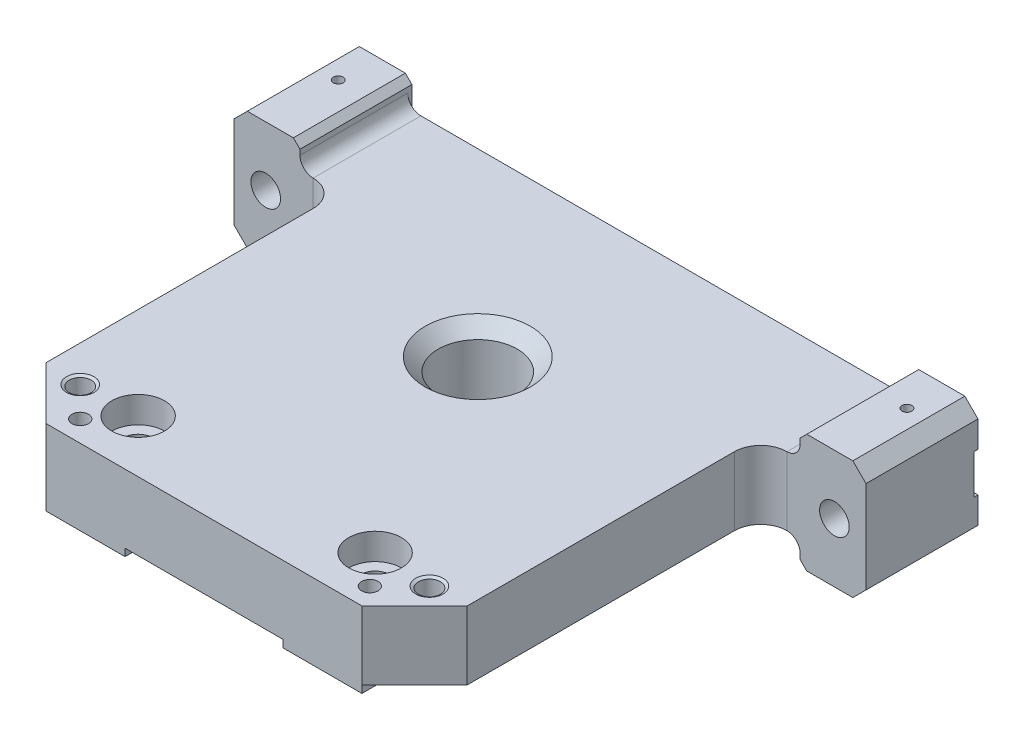
from build123d import *

# Parameters (mm, degrees)
SKETCH1_W                                     = 152.4
SKETCH1_H                                     = 16.51
EXTRUDE1_DEPTH                                = 11.1252
SKETCH2_W                                     = 101.6
SKETCH2_H                                     = 16.51
EXTRUDE2_DEPTH                                = 99.3648
SKETCH4_W                                     = 19.05
SKETCH4_H                                     = 19.05
EXTRUDE4_DEPTH                                = 2.54
SKETCH23_W                                    = 25.4
SKETCH23_H                                    = 15.8877
EXTRUDE17_DEPTH                               = 16.51
SKETCH45_W                                    = 15.875
SKETCH45_H                                    = 6.0325
EXTRUDE20_DEPTH                               = 27.0129
EXTRUDE21_DEPTH                               = 1.016
FILLET3_R                                     = 3.175
F_1_4_CLEARANCE_HOLE1_D                       = 7.14248
CBORE_FOR_SOCKET_HEAD_CAP_SCREW0_AT_2_COUNT   = 2
CBORE_FOR_SOCKET_HEAD_CAP_SCREW0_AT_2_PITCH   = 57.15
F_1_8_PRESS_PIN_HOLES_AT_2_COUNT              = 2
F_1_8_PRESS_PIN_HOLES_AT_2_PITCH              = 137.16
F_3_32_0_09375_DIAMETER_HOLE1_D               = 2.38125
F_3_32_0_09375_DIAMETER_HOLE1_DEPTH           = 12.7
F_3_32_0_09375_DIAMETER_HOLE1_TIP             = 0.715399675
F_3_32_0_09375_DIAMETER_HOLE2_D               = 2.38125
F_3_32_0_09375_DIAMETER_HOLE2_DEPTH           = 4.191
F_3_32_0_09375_DIAMETER_HOLE2_TIP             = 0.715399675
FILLET4_R                                     = 6.35
CHAMFER6_SIZE                                 = 3.175
CHAMFER7_SIZE                                 = 12.7
CHAMFER8_SIZE                                 = 1.5875
CHAMFER9_SIZE                                 = 0.762
CBORE_FOR_6_SOCKET_HEAD_CAP_SCREW2_AT_2_COUNT = 2
CBORE_FOR_6_SOCKET_HEAD_CAP_SCREW2_AT_2_PITCH = 69.85
TAPPED_HOLE_FOR_8_32_HELICOIL2_AT_2_COUNT     = 2
TAPPED_HOLE_FOR_8_32_HELICOIL2_AT_2_PITCH     = 84.218409794


with BuildPart() as part:
    # Sketch1 → Extrude1 (new body)
    with BuildSketch(Plane.XY):
        with Locations((0, 36.195)):
            Rectangle(SKETCH1_W, SKETCH1_H)
    extrude(amount=EXTRUDE1_DEPTH)

    # Sketch2 → Extrude2 (add)
    with BuildSketch(Plane.XY.offset(11.1252)):
        with Locations((0, 36.195)):
            Rectangle(SKETCH2_W, SKETCH2_H)
    extrude(amount=EXTRUDE2_DEPTH)

    # Sketch4 → Extrude4 (add)
    with BuildSketch(Plane.XZ.offset(-27.94)):
        with Locations((-28.575, 100.965)):
            Rectangle(SKETCH4_W, SKETCH4_H)
        with Locations((28.575, 100.965)):
            Rectangle(SKETCH4_W, SKETCH4_H)
    extrude(amount=EXTRUDE4_DEPTH)

    # Sketch23 → Extrude17 (add)
    with BuildSketch(Plane(origin=(0, 44.45, 0), x_dir=(1, 0, 0), z_dir=(0, 1, 0))):
        with Locations((63.5, -19.06905)):
            Rectangle(SKETCH23_W, SKETCH23_H)
        with Locations((-63.5, -19.06905)):
            Rectangle(SKETCH23_W, SKETCH23_H)
    extrude(amount=-EXTRUDE17_DEPTH)

    # Sketch45 → Extrude20 (add)
    with BuildSketch(Plane(origin=(0, 0, 0), x_dir=(-1, 0, 0), z_dir=(0, 0, -1))):
        with Locations((-68.2625, 47.46625)):
            Rectangle(SKETCH45_W, SKETCH45_H)
        with Locations((-68.2625, 24.92375)):
            Rectangle(SKETCH45_W, SKETCH45_H)
        with Locations((68.2625, 47.46625)):
            Rectangle(SKETCH45_W, SKETCH45_H)
        with Locations((68.2625, 24.92375)):
            Rectangle(SKETCH45_W, SKETCH45_H)
    extrude(amount=-EXTRUDE20_DEPTH)

    # Sketch46 → Extrude21 (cut)
    with BuildSketch(Plane(origin=(0, 0, 0), x_dir=(-1, 0, 0), z_dir=(0, 0, -1))):
        Polygon((-60.325, 44.45), (60.325, 44.45), (60.325, 40.9575), (76.2, 40.9575), (76.2, 31.4325), (60.325, 31.4325), (60.325, 27.94), (-60.325, 27.94), (-60.325, 31.4325), (-76.2, 31.4325), (-76.2, 40.9575), (-60.325, 40.9575), align=None)
    extrude(amount=-EXTRUDE21_DEPTH, mode=Mode.SUBTRACT)

    # Fillet3
    fillet3_edges = [part.edges().sort_by_distance(p)[0] for p in [
        (-60.325, 44.45, 14.01445),
        (-60.325, 27.94, 14.01445),
        (60.325, 27.94, 14.01445),
        (60.325, 44.45, 14.01445),
    ]]
    fillet(fillet3_edges, radius=FILLET3_R)

    # 1/4 Clearance Hole1 (through all)
    with Locations(Plane(origin=(56.815772276, 10.084895152, 27.0129), x_dir=(1, 0, 0), z_dir=(0, 0, 1))):
        with Locations((-125.395772276, 26.110104848), (11.764227724, 26.110104848)):
            Hole(F_1_4_CLEARANCE_HOLE1_D / 2)

    # Sketch30 → 3/4 (0.75) Diameter Hole1 (revolve, cut)
    with BuildSketch(Plane(origin=(0, 44.45, 44.45), x_dir=(0, 0, 1), z_dir=(1, 0, 0))):
        Polygon((0, 0), (0, 22.5425), (10.16, 22.5425), (9.525, 21.9075), (9.525, 3.175), (12.7, 0), align=None)
    revolve(axis=Axis((0, 50.8, 44.45), (0, -1, 0)), mode=Mode.SUBTRACT)

    # Sketch7 → CBORE for  Socket Head Cap Screw0 (revolve, cut)
    with BuildSketch(Plane(origin=(-28.575, 44.45, 97.79), x_dir=(0, 0, 1), z_dir=(1, 0, 0))):
        Polygon((0, 0), (0, 19.05), (4.064, 19.05), (3.57124, 18.55724), (3.57124, 6.35), (6.35, 6.35), (6.35, 0), align=None)
    cbore_for_socket_head_cap_screw0 = revolve(axis=Axis((-28.575, 50.8, 97.79), (0, -1, 0)), mode=Mode.SUBTRACT)

    # CBORE for  Socket Head Cap Screw0 at 2: CBORE for  Socket Head Cap Screw0 ×2
    with Locations(*[(i * CBORE_FOR_SOCKET_HEAD_CAP_SCREW0_AT_2_PITCH, 0, 0) for i in range(1, CBORE_FOR_SOCKET_HEAD_CAP_SCREW0_AT_2_COUNT)]):
        add(cbore_for_socket_head_cap_screw0, mode=Mode.SUBTRACT)

    # Sketch47 → 1/8" Press Pin Holes (revolve, cut)
    with BuildSketch(Plane(origin=(68.58, 45.72, 0), x_dir=(0, 1, 0), z_dir=(1, 0, 0))):
        Polygon((0, 0), (0, 7.303866233), (1.5875, 6.35), (1.5875, 1.524), (1.6002, 1.524), (1.6002, 0.3048), (1.905, 0), align=None)
    f_1_8_press_pin_holes = revolve(axis=Axis((68.58, 45.72, -6.35), (0, 0, 1)), mode=Mode.SUBTRACT)

    # 1/8" Press Pin Holes at 2: 1/8" Press Pin Holes ×2
    with Locations(*[(-i * F_1_8_PRESS_PIN_HOLES_AT_2_PITCH, 0, 0) for i in range(1, F_1_8_PRESS_PIN_HOLES_AT_2_COUNT)]):
        add(f_1_8_press_pin_holes, mode=Mode.SUBTRACT)

    # 3/32 (0.09375) Diameter Hole1
    with Locations(Plane(origin=(0, 0, 0), x_dir=(-1, 0, 0), z_dir=(0, 0, -1))):
        with Locations((-68.58, 45.72), (68.58, 45.72)):
            Hole(F_3_32_0_09375_DIAMETER_HOLE1_D / 2, depth=F_3_32_0_09375_DIAMETER_HOLE1_DEPTH)
            with Locations((0, 0, -(F_3_32_0_09375_DIAMETER_HOLE1_DEPTH + F_3_32_0_09375_DIAMETER_HOLE1_TIP / 2))):  # 118° drill point
                Cone(0, F_3_32_0_09375_DIAMETER_HOLE1_D / 2, F_3_32_0_09375_DIAMETER_HOLE1_TIP, mode=Mode.SUBTRACT)

    # 3/32 (0.09375) Diameter Hole2
    with Locations(Plane(origin=(0, 50.4825, 0), x_dir=(-1, 0, 0), z_dir=(0, 1, 0))):
        with Locations((-68.58, 9.525), (68.58, 9.525)):
            Hole(F_3_32_0_09375_DIAMETER_HOLE2_D / 2, depth=F_3_32_0_09375_DIAMETER_HOLE2_DEPTH)
            with Locations((0, 0, -(F_3_32_0_09375_DIAMETER_HOLE2_DEPTH + F_3_32_0_09375_DIAMETER_HOLE2_TIP / 2))):  # 118° drill point
                Cone(0, F_3_32_0_09375_DIAMETER_HOLE2_D / 2, F_3_32_0_09375_DIAMETER_HOLE2_TIP, mode=Mode.SUBTRACT)

    # Fillet4
    fillet4_edges = [part.edges().sort_by_distance(p)[0] for p in [
        (50.8, 36.195, 27.0129),
        (-50.8, 36.195, 27.0129),
    ]]
    fillet(fillet4_edges, radius=FILLET4_R)

    # Chamfer6
    chamfer6_edges = [part.edges().sort_by_distance(p)[0] for p in [
        (-76.2, 50.4825, 13.50645),
        (-76.2, 21.9075, 13.50645),
        (76.2, 50.4825, 13.50645),
        (76.2, 21.9075, 13.50645),
    ]]
    chamfer(chamfer6_edges, length=CHAMFER6_SIZE)

    # Chamfer7
    chamfer7_edges = [part.edges().sort_by_distance(p)[0] for p in [
        (50.8, 36.195, 110.49),
        (-50.8, 36.195, 110.49),
    ]]
    chamfer(chamfer7_edges, length=CHAMFER7_SIZE)

    # Chamfer8
    chamfer8_edges = [part.edges().sort_by_distance(p)[0] for p in [
        (-60.325, 50.4825, 13.50645),
        (-60.325, 21.9075, 13.50645),
        (60.325, 50.4825, 13.50645),
        (60.325, 21.9075, 13.50645),
    ]]
    chamfer(chamfer8_edges, length=CHAMFER8_SIZE)

    # Chamfer9
    chamfer9_edges = [part.edges().sort_by_distance(p)[0] for p in [
        (28.575, 25.4, 91.44),
        (38.1, 25.4, 100.965),
        (28.575, 25.4, 110.49),
        (19.05, 25.4, 100.965),
        (-19.05, 25.4, 100.965),
        (-28.575, 25.4, 91.44),
        (-38.1, 25.4, 100.965),
        (-28.575, 25.4, 110.49),
    ]]
    chamfer(chamfer9_edges, length=CHAMFER9_SIZE)

    # Sketch53 → CBORE for #6 Socket Head Cap Screw2 (revolve, cut)
    with BuildSketch(Plane(origin=(-34.925, 44.45, 105.41), x_dir=(0, 0, 1), z_dir=(1, 0, 0))):
        Polygon((0, 0), (0, 19.05), (1.905, 19.05), (1.63195, 18.77695), (1.63195, 12.7), (1.984375, 12.7), (1.984375, 0), align=None)
    cbore_for_6_socket_head_cap_screw2 = revolve(axis=Axis((-34.925, 50.8, 105.41), (0, -1, 0)), mode=Mode.SUBTRACT)

    # CBORE for #6 Socket Head Cap Screw2 at 2: CBORE for #6 Socket Head Cap Screw2 ×2
    with Locations(*[(i * CBORE_FOR_6_SOCKET_HEAD_CAP_SCREW2_AT_2_PITCH, 0, 0) for i in range(1, CBORE_FOR_6_SOCKET_HEAD_CAP_SCREW2_AT_2_COUNT)]):
        add(cbore_for_6_socket_head_cap_screw2, mode=Mode.SUBTRACT)

    # Sketch55 → Tapped Hole for #8-32 Helicoil2 (revolve, cut)
    with BuildSketch(Plane(origin=(-42.109204897, 44.45, 98.225795103), x_dir=(0, 0, 1), z_dir=(1, 0, 0))):
        Polygon((0, 0), (0, 22.5425), (2.1971, 22.5425), (2.1971, 10.3632), (2.63779, 10.3632), (2.63779, 0.383481822), (3.302, 0), align=None)
    tapped_hole_for_8_32_helicoil2 = revolve(axis=Axis((-42.109204897, 50.8, 98.225795103), (0, -1, 0)), mode=Mode.SUBTRACT)

    # Tapped Hole for #8-32 Helicoil2 at 2: Tapped Hole for #8-32 Helicoil2 ×2
    with Locations(*[(i * TAPPED_HOLE_FOR_8_32_HELICOIL2_AT_2_PITCH, 0, 0) for i in range(1, TAPPED_HOLE_FOR_8_32_HELICOIL2_AT_2_COUNT)]):
        add(tapped_hole_for_8_32_helicoil2, mode=Mode.SUBTRACT)


solid = part.part
